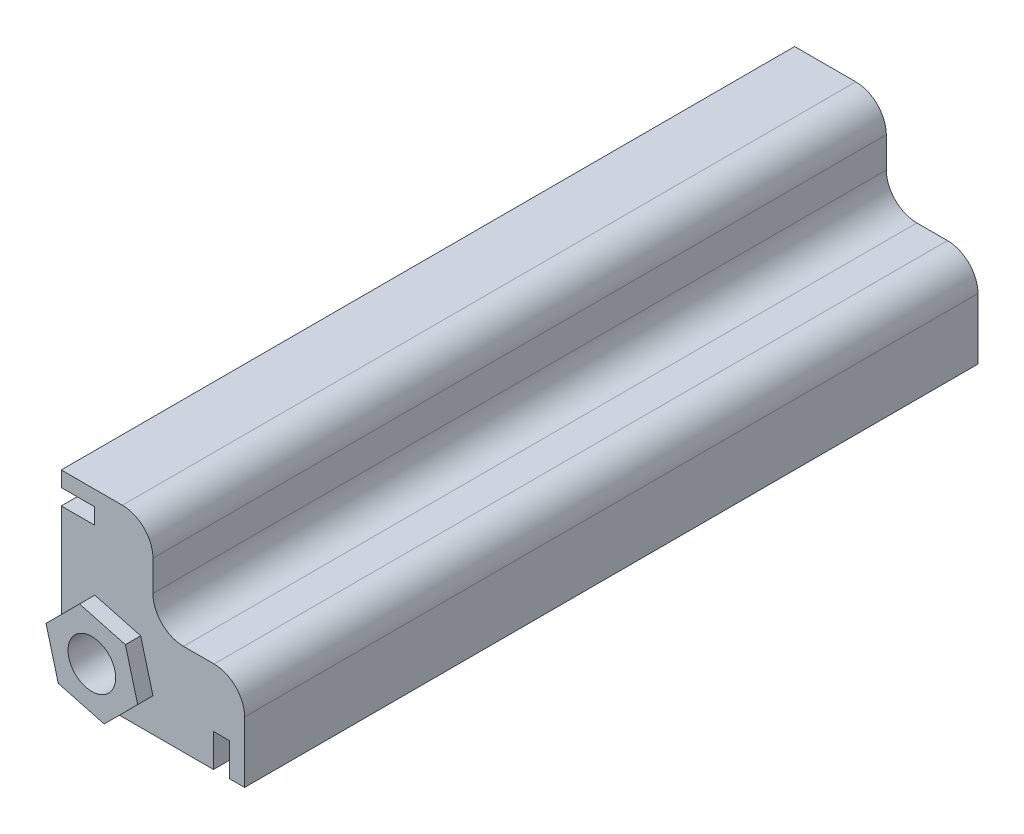
from build123d import *

# Parameters (mm, degrees)
BOSS_EXTRUDE1_DEPTH = 152.4
SKETCH2_W           = 6.858
SKETCH2_H           = 3.302
SKETCH2_W_2         = 3.302
SKETCH2_H_2         = 6.858
CUT_EXTRUDE1_DEPTH  = 153.4
BOSS_EXTRUDE2_DEPTH = 3.175
FILLET1_R           = 6.35
SKETCH4_R           = 4.953
CUT_EXTRUDE2_DEPTH  = 156.575


with BuildPart() as part:
    # Sketch1 → Boss-Extrude1 (new body)
    with BuildSketch(Plane.XY):
        Polygon((0, 0), (0, 38.1), (19.05, 38.1), (19.05, 19.05), (38.1, 19.05), (38.1, 0), align=None)
    extrude(amount=BOSS_EXTRUDE1_DEPTH)

    # Sketch2 → Cut-Extrude1 (cut, through all)
    with BuildSketch(Plane.XY.offset(152.4)):
        with Locations((3.429, 33.274)):
            Rectangle(SKETCH2_W, SKETCH2_H)
        with Locations((33.274, 3.429)):
            Rectangle(SKETCH2_W_2, SKETCH2_H_2)
    extrude(amount=-CUT_EXTRUDE1_DEPTH, mode=Mode.SUBTRACT)

    # Sketch3 → Boss-Extrude2 (add)
    with BuildSketch(Plane.XY.offset(152.4)):
        Polygon((16.497783942, 16.497783942), (6.972783942, 19.05), (0, 12.077216058), (2.552216058, 2.552216058), (12.077216058, 0), (19.05, 6.972783942), align=None)
    extrude(amount=BOSS_EXTRUDE2_DEPTH)

    # Fillet1
    fillet1_edges = [part.edges().sort_by_distance(p)[0] for p in [
        (19.05, 38.1, 76.2),
        (19.05, 19.05, 76.2),
        (38.1, 19.05, 76.2),
    ]]
    fillet(fillet1_edges, radius=FILLET1_R)

    # Sketch4 → Cut-Extrude2 (cut, through all)
    with BuildSketch(Plane.XY.offset(155.575)):
        with Locations((9.525, 9.525)):
            Circle(SKETCH4_R)
    extrude(amount=-CUT_EXTRUDE2_DEPTH, mode=Mode.SUBTRACT)


solid = part.part
